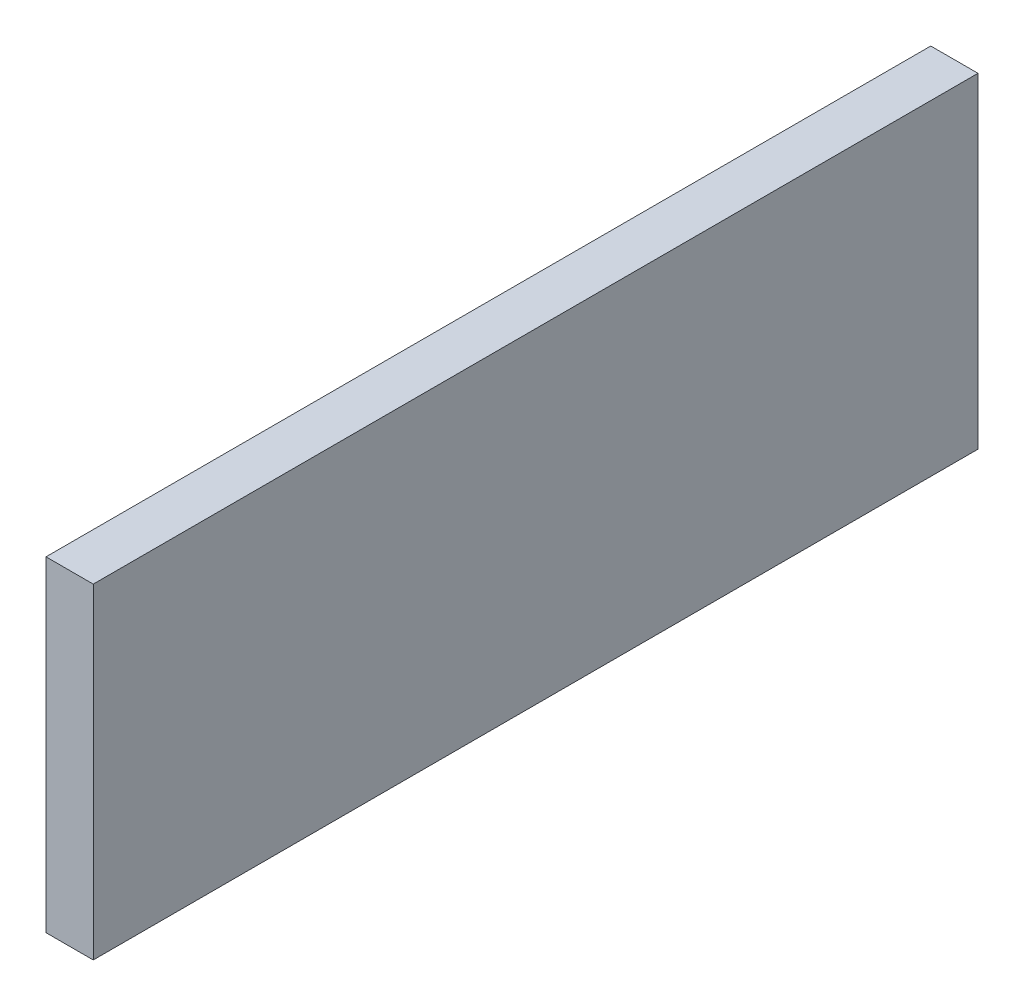
from build123d import *

# Parameters (mm, degrees)
SKETCH_1_W      = 337
SKETCH_1_H      = 124
EXTRUDE_1_DEPTH = 18


with BuildPart() as part:
    # Эскиз1 → Бобышка-Вытянуть1 (new body)
    with BuildSketch(Plane(origin=(0, 0, 0), x_dir=(0, 0, -1), z_dir=(1, 0, 0))):
        with Locations((136.848471307, -46.326505939)):
            Rectangle(SKETCH_1_W, SKETCH_1_H)
    extrude(amount=EXTRUDE_1_DEPTH)


solid = part.part
